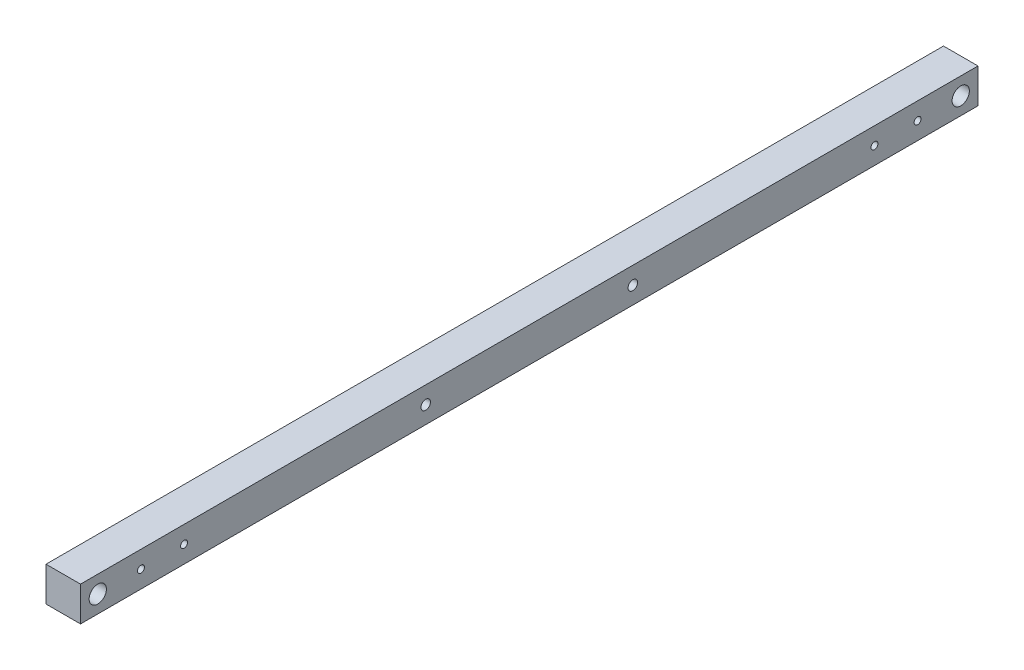
from build123d import *

# Parameters (mm, degrees)
SKETCH1_W               = 25.4
SKETCH1_H               = 25.4
BOSS_EXTRUDE1_DEPTH     = 660.4
SKETCH2_R               = 6.35
CUT_EXTRUDE4_DEPTH      = 26.4
CUT_EXTRUDE4_DEPTH_BACK = 1
SKETCH3_R               = 2.55
CUT_EXTRUDE5_DEPTH      = 26.4
SKETCH10_R              = 3.5
CUT_EXTRUDE6_DEPTH      = 26.4


with BuildPart() as part:
    # Sketch1 → Boss-Extrude1 (new body)
    with BuildSketch(Plane.XY):
        Rectangle(SKETCH1_W, SKETCH1_H)
    extrude(amount=BOSS_EXTRUDE1_DEPTH)

    # Sketch2 → Cut-Extrude4 (cut, two sides)
    with BuildSketch(Plane(origin=(-12.7, 0, 0), x_dir=(0, 0, -1), z_dir=(1, 0, 0))) as cut_extrude4_sk:
        with Locations((-12.7, 0)):
            Circle(SKETCH2_R)
        with Locations((-647.7, 0)):
            Circle(SKETCH2_R)
    extrude(amount=CUT_EXTRUDE4_DEPTH, mode=Mode.SUBTRACT)
    extrude(cut_extrude4_sk.sketch, amount=-CUT_EXTRUDE4_DEPTH_BACK, mode=Mode.SUBTRACT)

    # Sketch3 → Cut-Extrude5 (cut, through all)
    with BuildSketch(Plane.ZY.offset(12.7)):
        with Locations((584.2, 0)):
            Circle(SKETCH3_R)
        with Locations((76.2, 0)):
            Circle(SKETCH3_R)
        with Locations((615.95, 0)):
            Circle(SKETCH3_R)
        with Locations((44.45, 0)):
            Circle(SKETCH3_R)
    extrude(amount=-CUT_EXTRUDE5_DEPTH, mode=Mode.SUBTRACT)

    # Sketch10 → Cut-Extrude6 (cut, through all)
    with BuildSketch(Plane.ZY.offset(12.7)):
        with Locations((406.4, 0)):
            Circle(SKETCH10_R)
        with Locations((254, 0)):
            Circle(SKETCH10_R)
    extrude(amount=-CUT_EXTRUDE6_DEPTH, mode=Mode.SUBTRACT)


solid = part.part
